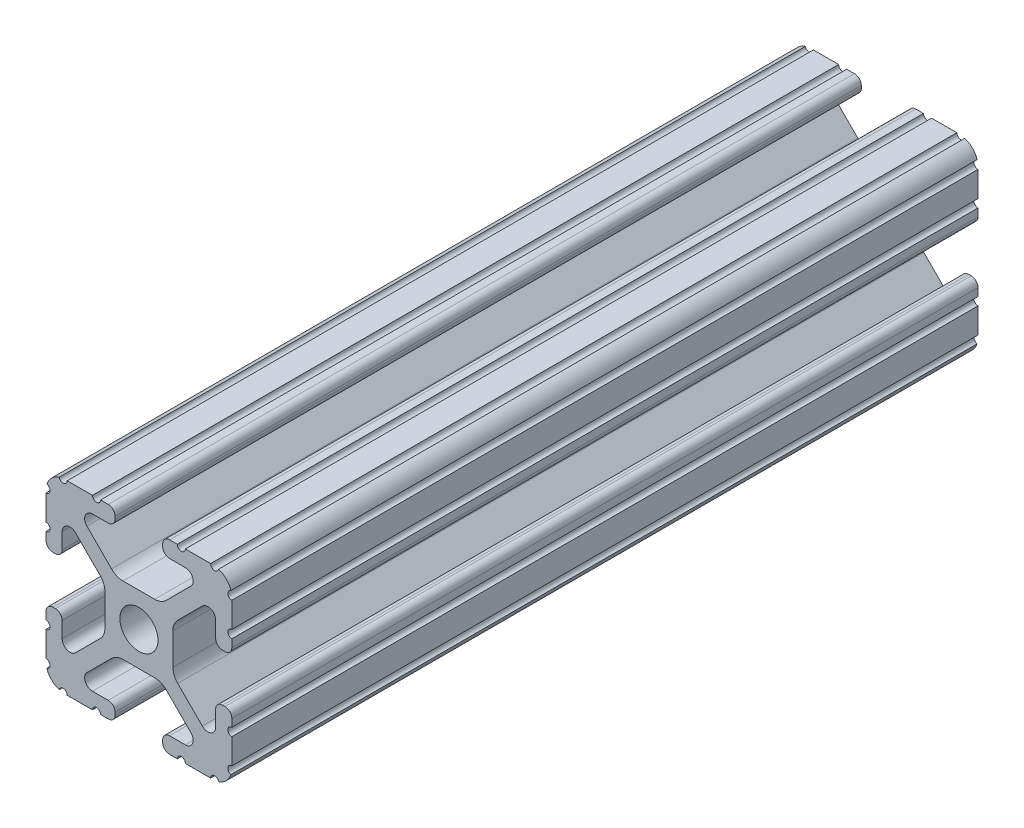
from build123d import *

# Parameters (mm, degrees)
BOSS_EXTRUDE1_DEPTH     = 51.000025
SKETCH5_R               = 0.55245
CUT_EXTRUDE1_DEPTH      = 52.000025
CUT_EXTRUDE1_DEPTH_BACK = 52.000025


with BuildPart() as part:
    # Sketch4 → Boss-Extrude1 (new body, symmetric)
    with BuildSketch(Plane.XY):
        with BuildLine():
            Line((4.190365, -12.7), (10.11729625, -12.7))
            ThreePointArc((10.11729625, -12.7), (11.943543585, -11.943543585), (12.7, -10.11729625))
            Line((12.7, -10.11729625), (12.7, -4.190365))
            ThreePointArc((12.7, -4.190365), (12.42492494, -3.52627506), (11.760835, -3.2512))
            Line((11.760835, -3.2512), (11.429365, -3.2512))
            ThreePointArc((11.429365, -3.2512), (10.76527506, -3.52627506), (10.4902, -4.190365))
            Line((10.4902, -4.190365), (10.4902, -6.348478019))
            ThreePointArc((10.4902, -6.348478019), (9.830707141, -7.335478831), (8.666460301, -7.103895736))
            Line((8.666460301, -7.103895736), (5.299899128, -3.737334563))
            ThreePointArc((5.299899128, -3.737334563), (4.817571085, -3.015479634), (4.6482, -2.16399369))
            Line((4.6482, -2.16399369), (4.6482, 0))
            Line((4.6482, 0), (2.6035, 0))
            ThreePointArc((2.6035, 0), (1.840952505, -1.840952505), (0, -2.6035))
            Line((0, -2.6035), (0, -4.6482))
            Line((0, -4.6482), (2.16399369, -4.6482))
            ThreePointArc((2.16399369, -4.6482), (3.015479634, -4.817571085), (3.737334563, -5.299899128))
            Line((3.737334563, -5.299899128), (7.103895736, -8.666460301))
            ThreePointArc((7.103895736, -8.666460301), (7.335478831, -9.830707141), (6.348478019, -10.4902))
            Line((6.348478019, -10.4902), (4.190365, -10.4902))
            ThreePointArc((4.190365, -10.4902), (3.52627506, -10.76527506), (3.2512, -11.429365))
            Line((3.2512, -11.429365), (3.2512, -11.760835))
            ThreePointArc((3.2512, -11.760835), (3.52627506, -12.42492494), (4.190365, -12.7))
        make_face()
    extrude(amount=BOSS_EXTRUDE1_DEPTH, both=True)

    # Sketch5 → Cut-Extrude1 (cut, two sides)
    with BuildSketch(Plane.XY) as cut_extrude1_sk:
        with Locations((10.356153152, -12.7)):
            Circle(SKETCH5_R)
        with Locations((5.796028019, -12.7)):
            Circle(SKETCH5_R)
        with Locations((12.7, -10.356153152)):
            Circle(SKETCH5_R)
        with Locations((12.7, -5.796028019)):
            Circle(SKETCH5_R)
    extrude(amount=CUT_EXTRUDE1_DEPTH, mode=Mode.SUBTRACT)
    extrude(cut_extrude1_sk.sketch, amount=-CUT_EXTRUDE1_DEPTH_BACK, mode=Mode.SUBTRACT)

    # Mirror1: part across plane


with BuildPart() as part_1:
    add(part.part)
    add(part.part.mirror(Plane(origin=(0, 0, 0), x_dir=(0, 0, 1), z_dir=(1, 0, 0))))

    # Mirror2: part across plane


with BuildPart() as part_2:
    add(part_1.part)
    add(part_1.part.mirror(Plane.ZX))


solid = part_2.part
